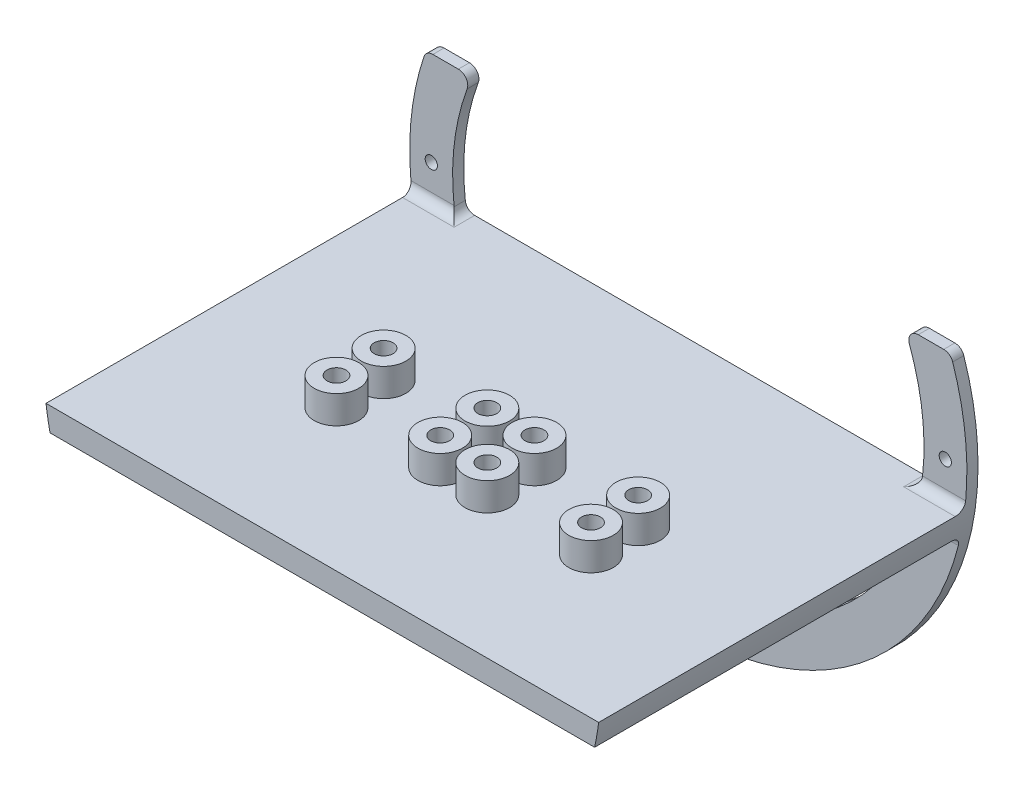
from build123d import *

# Parameters (mm, degrees)
BOSS_EXTRUDE1_DEPTH   = 3
BOSS_EXTRUDE1_2_DEPTH = 3
BOSS_EXTRUDE1_3_DEPTH = 3
BOSS_EXTRUDE2_DEPTH   = 101.6
SKETCH2_R             = 5.999999999999988
SKETCH2_R_2           = 2.5526999999999975
SKETCH2_R_3           = 6
SKETCH2_R_4           = 2.5527000000000024
SKETCH2_R_5           = 6.000000000000007
SKETCH2_R_6           = 2.5526999999999953
SKETCH2_R_7           = 5.999999999999999
SKETCH2_R_8           = 2.552699999999999
SKETCH2_R_9           = 5.9999999999999964
SKETCH2_R_10          = 6.0000000000000036
SKETCH2_R_11          = 2.5527000000000126
SKETCH2_R_12          = 2.552700000000004
BOSS_EXTRUDE3_DEPTH   = 7.54
SKETCH2_3_R           = 2.5526999999999953
SKETCH2_3_R_2         = 2.5526999999999975
SKETCH2_3_R_3         = 2.5527000000000024
SKETCH2_3_R_4         = 2.552699999999999
SKETCH2_3_R_5         = 2.5527000000000126
SKETCH2_3_R_6         = 2.552700000000004
CUT_EXTRUDE1_DEPTH    = 143.3044492382441
SKETCH3_R             = 1.6499999999999975
SKETCH3_R_2           = 1.6500000000000021
CUT_EXTRUDE2_DEPTH    = 145.87603838454444
FILLET1_R             = 2.5399999999999996
FILLET2_R             = 2.5399999999999996
FILLET3_R             = 2.5399999999999996


with BuildPart() as part:
    # Sketch1 → Boss-Extrude1 (new body)
    with BuildSketch(Plane.XY):
        with BuildLine():
            Line((-58.198711325939165, 25.400000000000002), (-70.62855831036053, 25.400000000000002))
            ThreePointArc((-70.62855831036052, 25.39999999999999), (-74.61164899798933, 8.164256414446488), (-74.45016873050051, -9.524999999999999))
            Line((-74.45016873050054, -9.525), (-62.78156078818072, -9.525))
            ThreePointArc((-62.7815607881806, -9.524999999999148), (-62.96026895155072, 8.261630199203937), (-58.198711325939165, 25.4))
        make_face()
    extrude(amount=BOSS_EXTRUDE1_DEPTH)



with BuildPart() as body_2:
    # Sketch1 → Boss-Extrude1 2 (new body)
    with BuildSketch(Plane.XY):
        with BuildLine():
            Line((-61.48361062104342, -15.875), (-73.35896416935016, -15.875))
            ThreePointArc((-73.35896416935012, -15.874999999999993), (1.421e-14, -75.05699999999997), (73.35896416935014, -15.874999999999961))
            Line((73.35896416935016, -15.875), (61.48361062104344, -15.875))
            ThreePointArc((61.483610621043105, -15.874999999998629), (1.78e-15, -63.50000000000001), (-61.48361062104309, -15.874999999998634))
        make_face()
    extrude(amount=BOSS_EXTRUDE1_2_DEPTH)


with BuildPart() as body_3:
    # Sketch1 → Boss-Extrude1 3 (new body)
    with BuildSketch(Plane.XY):
        with BuildLine():
            ThreePointArc((58.19871132593919, 25.399999999999977), (62.96026895155074, 8.261630199203923), (62.78156078818061, -9.524999999999146))
            Line((62.78156078818074, -9.525), (74.45016873050054, -9.525))
            ThreePointArc((74.45016873050054, -9.524999999999999), (74.61164899798936, 8.164256414446513), (70.62855831036052, 25.400000000000006))
            Line((70.62855831036053, 25.400000000000002), (58.198711325939165, 25.400000000000002))
        make_face()
    extrude(amount=BOSS_EXTRUDE1_3_DEPTH)


with BuildPart() as part_1:
    add(part.part)

    add(body_2.part)  # Boss-Extrude2 merges body 2

    add(body_3.part)  # Boss-Extrude2 merges body 3
    # Sketch1_3 → Boss-Extrude2 (add)
    with BuildSketch(Plane.XY):
        with BuildLine():
            ThreePointArc((-74.45016873050051, -9.524999999999999), (-73.97273529586036, -12.711714355214593), (-73.35896416935012, -15.874999999999993))
            Line((-73.35896416935016, -15.875), (73.35896416935016, -15.875))
            ThreePointArc((73.35896416935014, -15.874999999999991), (73.97273529586039, -12.711714355214575), (74.45016873050054, -9.524999999999999))
            Line((74.45016873050054, -9.525), (-74.45016873050054, -9.525))
        make_face()
    extrude(amount=BOSS_EXTRUDE2_DEPTH)

    # Sketch2 → Boss-Extrude3 (add)
    # profile 1 of 8: a face of its own
    with BuildSketch(Plane(origin=(0, -9.525, 0), x_dir=(1, 0, 0), z_dir=(0, 1, 0))):
        with Locations((-34.29, -50.8)):
            Circle(SKETCH2_R)
        with Locations((-34.29, -50.8)):
            Circle(SKETCH2_R_2, mode=Mode.SUBTRACT)
    # profile 2 of 8: a face of its own
    with BuildSketch(Plane(origin=(0, -9.525, 0), x_dir=(1, 0, 0), z_dir=(0, 1, 0))):
        with Locations((-6.349999999999996, -50.8)):
            Circle(SKETCH2_R_3)
        with Locations((-6.349999999999996, -50.8)):
            Circle(SKETCH2_R_4, mode=Mode.SUBTRACT)
    # profile 3 of 8: a face of its own
    with BuildSketch(Plane(origin=(0, -9.525, 0), x_dir=(1, 0, 0), z_dir=(0, 1, 0))):
        with Locations((-34.29, -63.5)):
            Circle(SKETCH2_R_5)
        with Locations((-34.29, -63.5)):
            Circle(SKETCH2_R_6, mode=Mode.SUBTRACT)
    # profile 4 of 8: a face of its own
    with BuildSketch(Plane(origin=(0, -9.525, 0), x_dir=(1, 0, 0), z_dir=(0, 1, 0))):
        with Locations((-6.349999999999996, -63.5)):
            Circle(SKETCH2_R_7)
        with Locations((-6.349999999999996, -63.5)):
            Circle(SKETCH2_R_8, mode=Mode.SUBTRACT)
    # profile 5 of 8: a face of its own
    with BuildSketch(Plane(origin=(0, -9.525, 0), x_dir=(1, 0, 0), z_dir=(0, 1, 0))):
        with Locations((6.350000000000014, -63.5)):
            Circle(SKETCH2_R_9)
        with Locations((6.350000000000014, -63.5)):
            Circle(SKETCH2_R_8, mode=Mode.SUBTRACT)
    # profile 6 of 8: a face of its own
    with BuildSketch(Plane(origin=(0, -9.525, 0), x_dir=(1, 0, 0), z_dir=(0, 1, 0))):
        with Locations((34.29000000000001, -63.499999999999986)):
            Circle(SKETCH2_R_10)
        with Locations((34.29000000000001, -63.499999999999986)):
            Circle(SKETCH2_R_11, mode=Mode.SUBTRACT)
    # profile 7 of 8: a face of its own
    with BuildSketch(Plane(origin=(0, -9.525, 0), x_dir=(1, 0, 0), z_dir=(0, 1, 0))):
        with Locations((6.35000000000001, -50.8)):
            Circle(SKETCH2_R_7)
        with Locations((6.35000000000001, -50.8)):
            Circle(SKETCH2_R_4, mode=Mode.SUBTRACT)
    # profile 8 of 8: a face of its own
    with BuildSketch(Plane(origin=(0, -9.525, 0), x_dir=(1, 0, 0), z_dir=(0, 1, 0))):
        with Locations((34.29000000000001, -50.79999999999999)):
            Circle(SKETCH2_R_10)
        with Locations((34.29000000000001, -50.79999999999999)):
            Circle(SKETCH2_R_12, mode=Mode.SUBTRACT)
    extrude(amount=BOSS_EXTRUDE3_DEPTH)

    # Sketch2_3 → Cut-Extrude1 (cut, through all)
    with BuildSketch(Plane(origin=(0, -9.525, 0), x_dir=(1, 0, 0), z_dir=(0, 1, 0))):
        with Locations((-34.29, -63.5)):
            Circle(SKETCH2_3_R)
        with Locations((-34.29, -50.8)):
            Circle(SKETCH2_3_R_2)
        with Locations((-6.349999999999996, -50.8)):
            Circle(SKETCH2_3_R_3)
        with Locations((-6.349999999999996, -63.5)):
            Circle(SKETCH2_3_R_4)
        with Locations((6.350000000000014, -63.5)):
            Circle(SKETCH2_3_R_4)
        with Locations((34.29000000000001, -63.499999999999986)):
            Circle(SKETCH2_3_R_5)
        with Locations((6.35000000000001, -50.8)):
            Circle(SKETCH2_3_R_3)
        with Locations((34.29000000000001, -50.79999999999999)):
            Circle(SKETCH2_3_R_6)
    extrude(amount=-CUT_EXTRUDE1_DEPTH, mode=Mode.SUBTRACT)

    # Sketch3 → Cut-Extrude2 (cut, through all)
    with BuildSketch(Plane.XY.offset(3)):
        with Locations((0, -69.24071309920174)):
            Circle(SKETCH3_R)
        with Locations((69.24071309920174, 0)):
            Circle(SKETCH3_R_2)
        with Locations((-69.24071309920174, 0)):
            Circle(SKETCH3_R_2)
    extrude(amount=-CUT_EXTRUDE2_DEPTH, mode=Mode.SUBTRACT)

    # Fillet1
    fillet1_edges = [part_1.edges().sort_by_distance(p)[0] for p in [
        (70.62855831036052, 25.400000000000002, 1.5),
        (58.198711325939186, 25.39999999999999, 1.5),
        (-70.62855831036052, 25.4, 1.5),
        (-58.19871132593916, 25.4, 1.5),
    ]]
    fillet(fillet1_edges, radius=FILLET1_R)

    # Fillet2
    fillet2_edges = [part_1.edges().sort_by_distance(p)[0] for p in [
        (-67.42128739519679, -15.875, 3),
        (-68.61586475934062, -9.525, 3),
        (68.61586475934064, -9.525, 3),
        (67.4212873951968, -15.875, 3),
    ]]
    fillet(fillet2_edges, radius=FILLET2_R)

    # Fillet3
    fillet3_edges = [part_1.edges().sort_by_distance(p)[0] for p in [
        (62.781560788180585, -9.524999999999785, 2.7699999999999996),
        (61.48361062104301, -15.874999999999657, 2.7699999999999996),
        (-61.483610621043, -15.87499999999966, 2.7699999999999996),
        (-62.781560788180556, -9.524999999999785, 2.7699999999999996),
    ]]
    fillet(fillet3_edges, radius=FILLET3_R)


solid = part_1.part
